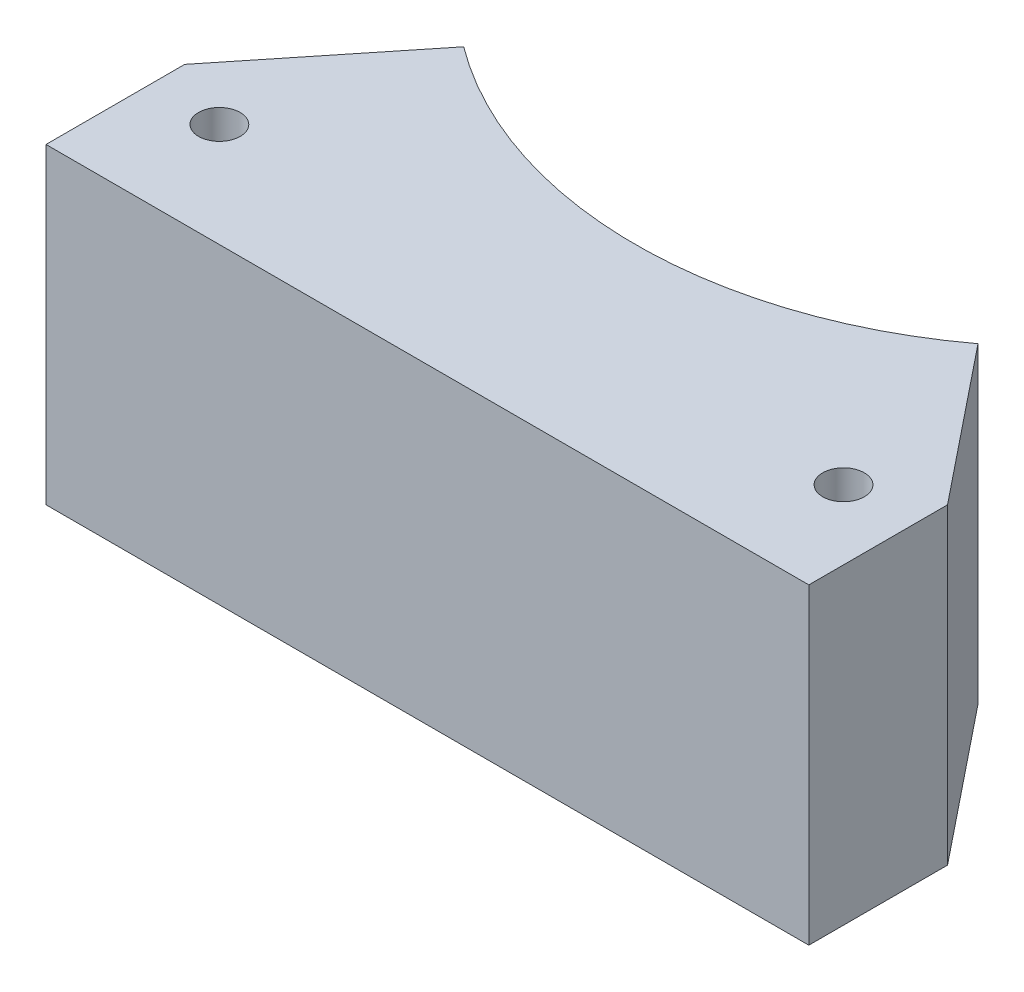
from build123d import *

# Parameters (mm, degrees)
BOSS_EXTRUDE1_DEPTH = 45
SKETCH2_R           = 3
CUT_EXTRUDE1_DEPTH  = 46
CUT_EXTRUDE3_DEPTH  = 46


with BuildPart() as part:
    # Sketch1 → Boss-Extrude1 (new body)
    with BuildSketch(Plane(origin=(0, 0, 0), x_dir=(1, 0, 0), z_dir=(0, 1, 0))):
        with BuildLine():
            Line((-33.134005589, -22.163352058), (76.865994411, -22.163352058))
            Line((76.865994411, -22.163352058), (76.865994411, -2.163352058))
            Line((76.865994411, -2.163352058), (62.388671822, 22.912106224))
            ThreePointArc((62.388671822, 22.912106224), (21.865994411, 7.836647942), (-18.656683, 22.912106224))
            Line((-18.656683, 22.912106224), (-33.134005589, -2.163352058))
            Line((-33.134005589, -2.163352058), (-33.134005589, -22.163352058))
        make_face()
    extrude(amount=BOSS_EXTRUDE1_DEPTH)

    # Sketch2 → Cut-Extrude1 (cut, through all)
    with BuildSketch(Plane(origin=(0, 45, 0), x_dir=(1, 0, 0), z_dir=(0, 1, 0))):
        with Locations((-23.134005589, -7.163352058)):
            Circle(SKETCH2_R)
        with Locations((66.865994411, -7.163352058)):
            Circle(SKETCH2_R)
    extrude(amount=-CUT_EXTRUDE1_DEPTH, mode=Mode.SUBTRACT)

    # Sketch3 → Cut-Extrude3 (cut, through all)
    with BuildSketch(Plane.XZ):
        Polygon((-12.082515606, -24.049109598), (-33.134005589, 2.163352058), (-36.114163106, -37.146188521), align=None)
        Polygon((79.846151928, -37.146188521), (55.814504429, -24.049109598), (76.865994411, 2.163352058), align=None)
    extrude(amount=-CUT_EXTRUDE3_DEPTH, mode=Mode.SUBTRACT)


solid = part.part
